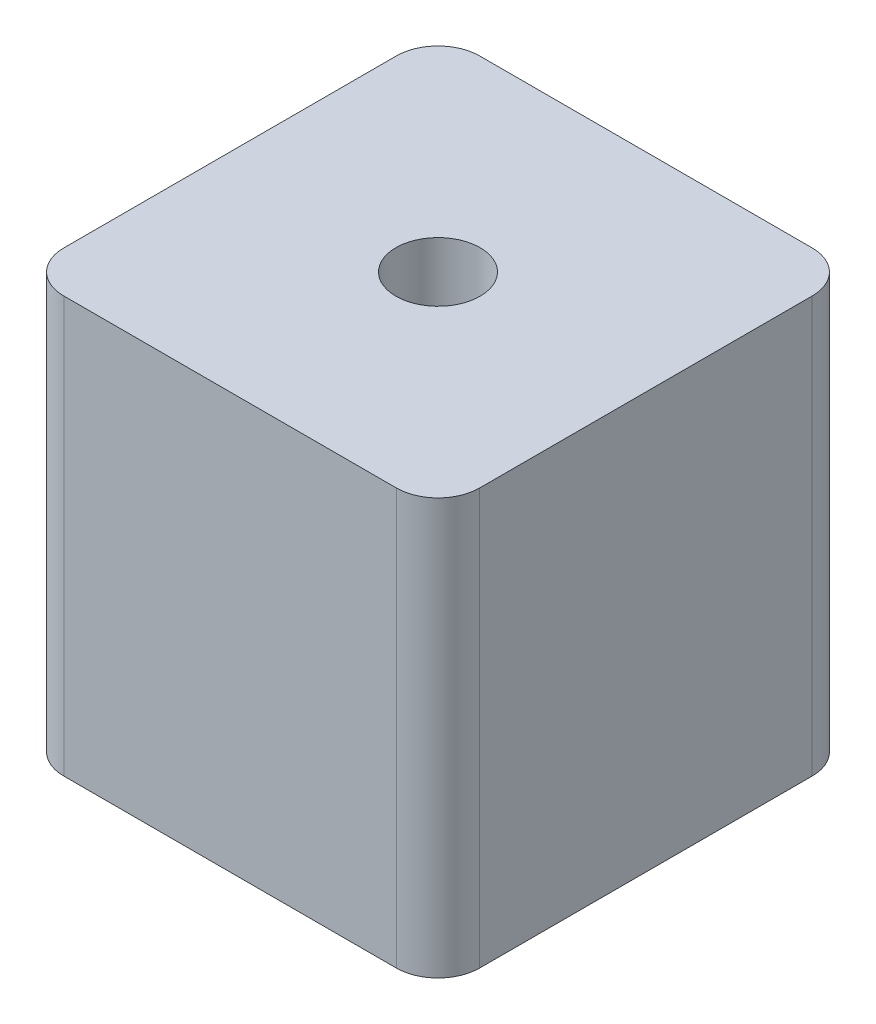
from build123d import *

# Parameters (mm, degrees)
SKETCH_1_W          = 20
SKETCH_1_H          = 20
EXTRUDE_1_DEPTH     = 20
SKETCH_2_R          = 2.025
CUT_EXTRUDE_1_DEPTH = 20
FILLET_1_R          = 2


with BuildPart() as part:
    # 草图1 → 凸台-拉伸1 (new body)
    with BuildSketch(Plane(origin=(0, 0, 0), x_dir=(1, 0, 0), z_dir=(0, 1, 0))):
        Rectangle(SKETCH_1_W, SKETCH_1_H)
    extrude(amount=EXTRUDE_1_DEPTH)

    # 草图2 → 切除-拉伸1 (cut)
    with BuildSketch(Plane(origin=(0, 20, 0), x_dir=(1, 0, 0), z_dir=(0, 1, 0))):
        Circle(SKETCH_2_R)
    extrude(amount=-CUT_EXTRUDE_1_DEPTH, mode=Mode.SUBTRACT)

    # 圆角1
    fillet_1_edges = [part.edges().sort_by_distance(p)[0] for p in [
        (10, 10, 10),
        (-10, 10, 10),
        (-10, 10, -10),
        (10, 10, -10),
    ]]
    fillet(fillet_1_edges, radius=FILLET_1_R)


solid = part.part
